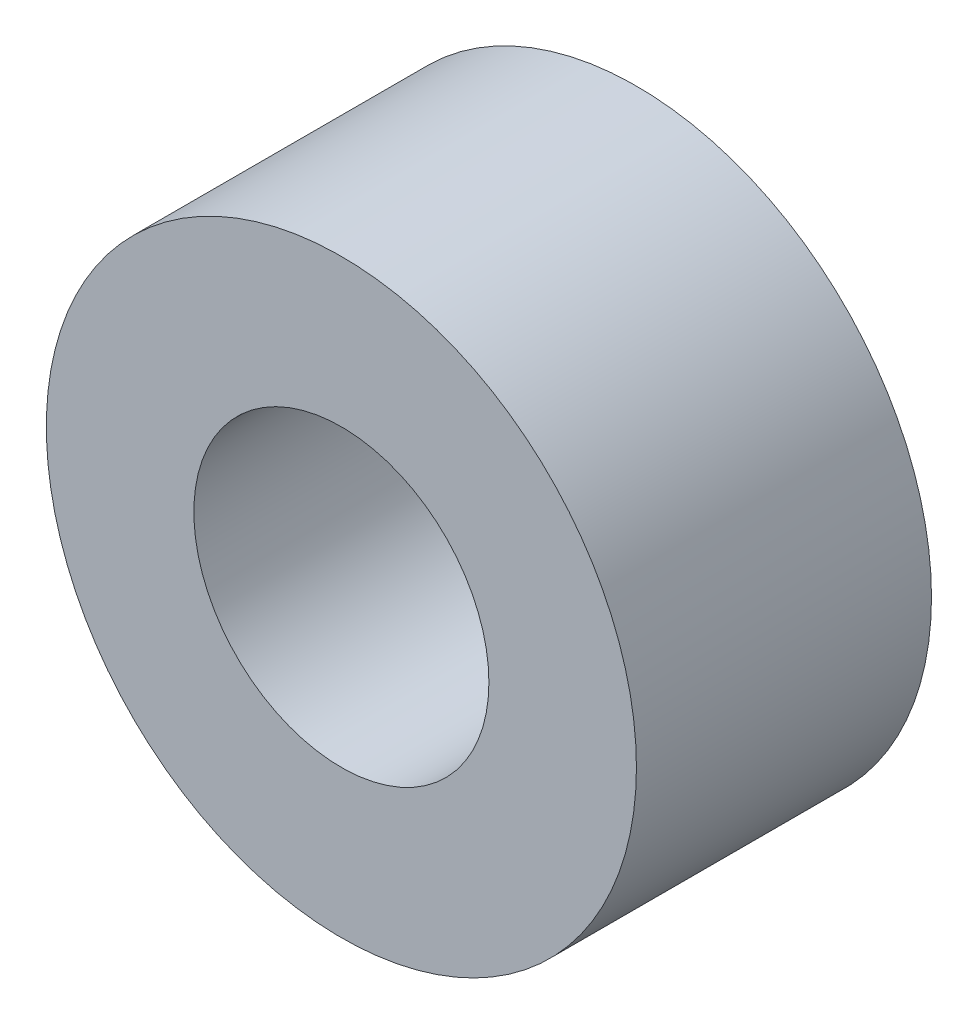
from build123d import *

# Parameters (mm, degrees)
SKETCH_1_R      = 10
SKETCH_1_R_2    = 5
EXTRUDE_1_DEPTH = 10


with BuildPart() as part:
    # 草图1 → 凸台-拉伸1 (new body)
    with BuildSketch(Plane.XY):
        Circle(SKETCH_1_R)
        Circle(SKETCH_1_R_2, mode=Mode.SUBTRACT)
    extrude(amount=EXTRUDE_1_DEPTH)


solid = part.part
